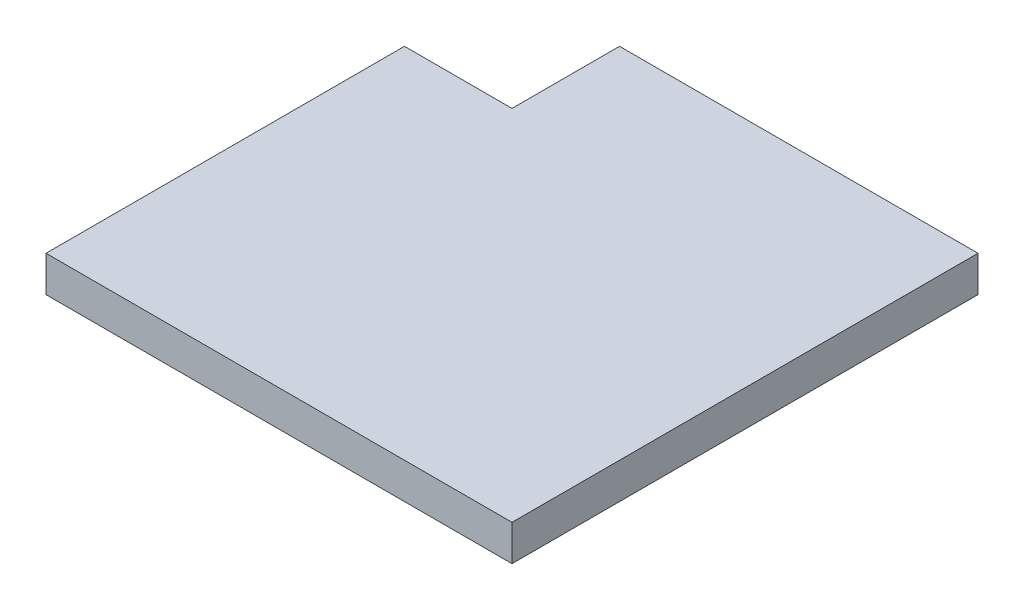
from build123d import *

# Parameters (mm, degrees)
BOSS_EXTRUDE1_DEPTH = 10


with BuildPart() as part:
    # Sketch1 → Boss-Extrude1 (new body)
    with BuildSketch(Plane(origin=(0, 0, 0), x_dir=(1, 0, 0), z_dir=(0, 1, 0))):
        Polygon((-65, -65), (65, -65), (65, 65), (-35, 65), (-35, 35), (-65, 35), align=None)
    extrude(amount=BOSS_EXTRUDE1_DEPTH)


solid = part.part
